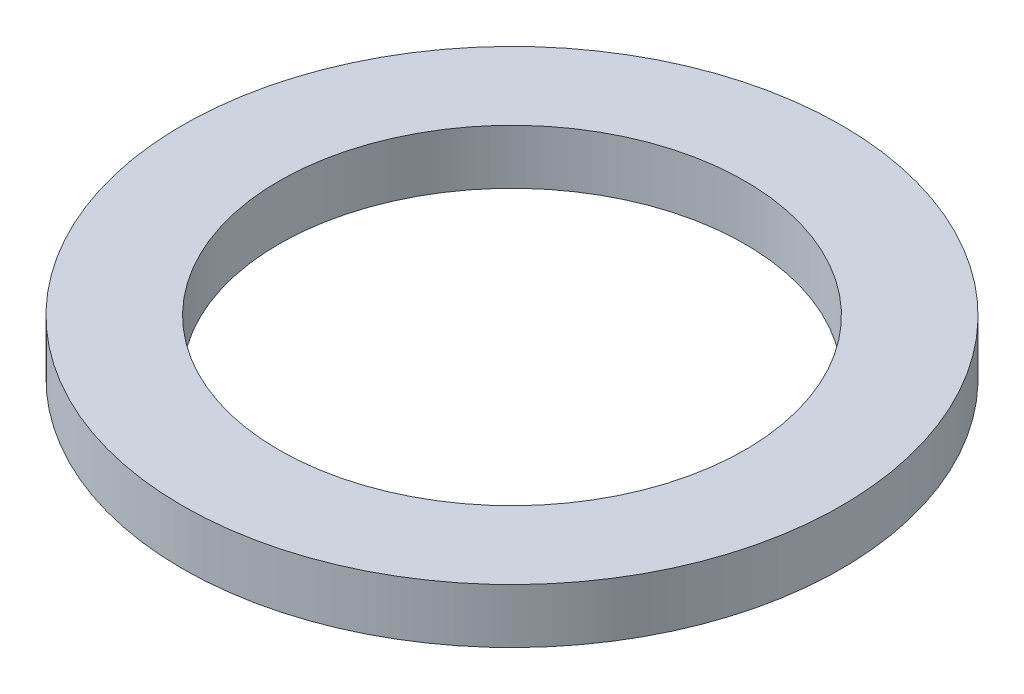
from build123d import *

# Parameters (mm, degrees)
SKETCH1_W = 11.2395
SKETCH1_H = 6.35


with BuildPart() as part:
    # Sketch1 → Revolve1 (revolve)
    with BuildSketch(Plane.XY):
        with Locations((32.73425, -3.175)):
            Rectangle(SKETCH1_W, SKETCH1_H)
    revolve(axis=Axis((0, 22.709640493, 0), (0, -1, 0)))


solid = part.part
